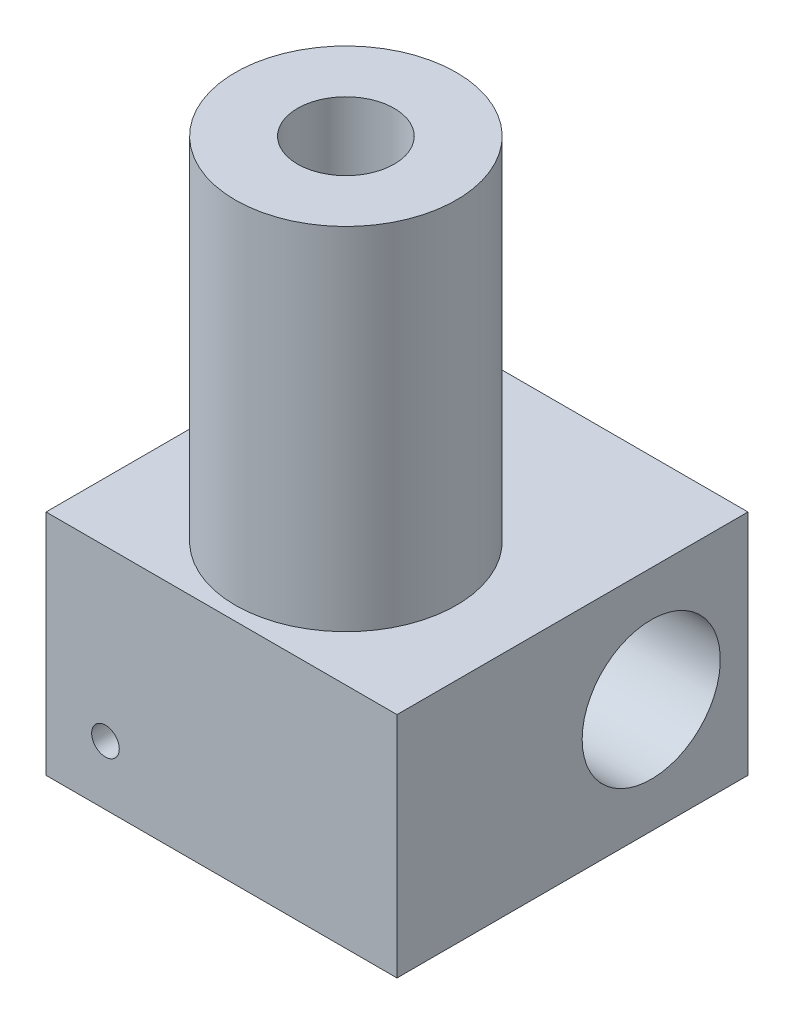
from build123d import *

# Parameters (mm, degrees)
SKETCH1_W       = 12.7
SKETCH1_H       = 12.7
EXTRUDE1_DEPTH  = 8.255
SKETCH2_R       = 4
EXTRUDE2_DEPTH  = 12.7
SKETCH4_R       = 4
EXTRUDE8_DEPTH  = 2.5
EXTRUDE8_TAPER  = 51
SKETCH5_R       = 0.25
EXTRUDE9_DEPTH  = 2.5
SKETCH3_R       = 1.75
EXTRUDE10_DEPTH = 20.955
SKETCH7_R       = 2.5
EXTRUDE11_DEPTH = 12.7
SKETCH8_R       = 0.5
EXTRUDE12_DEPTH = 2.5


with BuildPart() as part:
    # Sketch1 → Extrude1 (new body)
    with BuildSketch(Plane(origin=(0, 0, 0), x_dir=(1, 0, 0), z_dir=(0, 1, 0))):
        Rectangle(SKETCH1_W, SKETCH1_H)
    extrude(amount=EXTRUDE1_DEPTH)

    # Sketch2 → Extrude2 (add)
    with BuildSketch(Plane(origin=(0, 8.255, 0), x_dir=(1, 0, 0), z_dir=(0, 1, 0))):
        with Locations((0, -1.85)):
            Circle(SKETCH2_R)
    extrude(amount=EXTRUDE2_DEPTH)

    # Sketch4 → Extrude8 (add)
    with BuildSketch(Plane.XZ):
        with Locations((0, 1.85)):
            Circle(SKETCH4_R)
    extrude(amount=EXTRUDE8_DEPTH, taper=EXTRUDE8_TAPER)

    # Sketch5 → Extrude9 (cut)
    with BuildSketch(Plane.XZ.offset(2.5)):
        with Locations((0, 1.85)):
            Circle(SKETCH5_R)
    extrude(amount=-EXTRUDE9_DEPTH, mode=Mode.SUBTRACT)

    # Sketch3 → Extrude10 (cut)
    with BuildSketch(Plane(origin=(0, 20.955, 0), x_dir=(-1, 0, 0), z_dir=(0, 1, 0))):
        with Locations((0, 1.85)):
            Circle(SKETCH3_R)
    extrude(amount=-EXTRUDE10_DEPTH, mode=Mode.SUBTRACT)

    # Sketch7 → Extrude11 (cut)
    with BuildSketch(Plane.ZY.offset(6.35)):
        with Locations((-2.85, 4.1275)):
            Circle(SKETCH7_R)
    extrude(amount=-EXTRUDE11_DEPTH, mode=Mode.SUBTRACT)

    # Sketch8 → Extrude12 (cut)
    with BuildSketch(Plane.XY.offset(6.35)):
        with Locations((-4.199914645, 2.150085355)):
            Circle(SKETCH8_R)
    extrude(amount=-EXTRUDE12_DEPTH, mode=Mode.SUBTRACT)


solid = part.part
